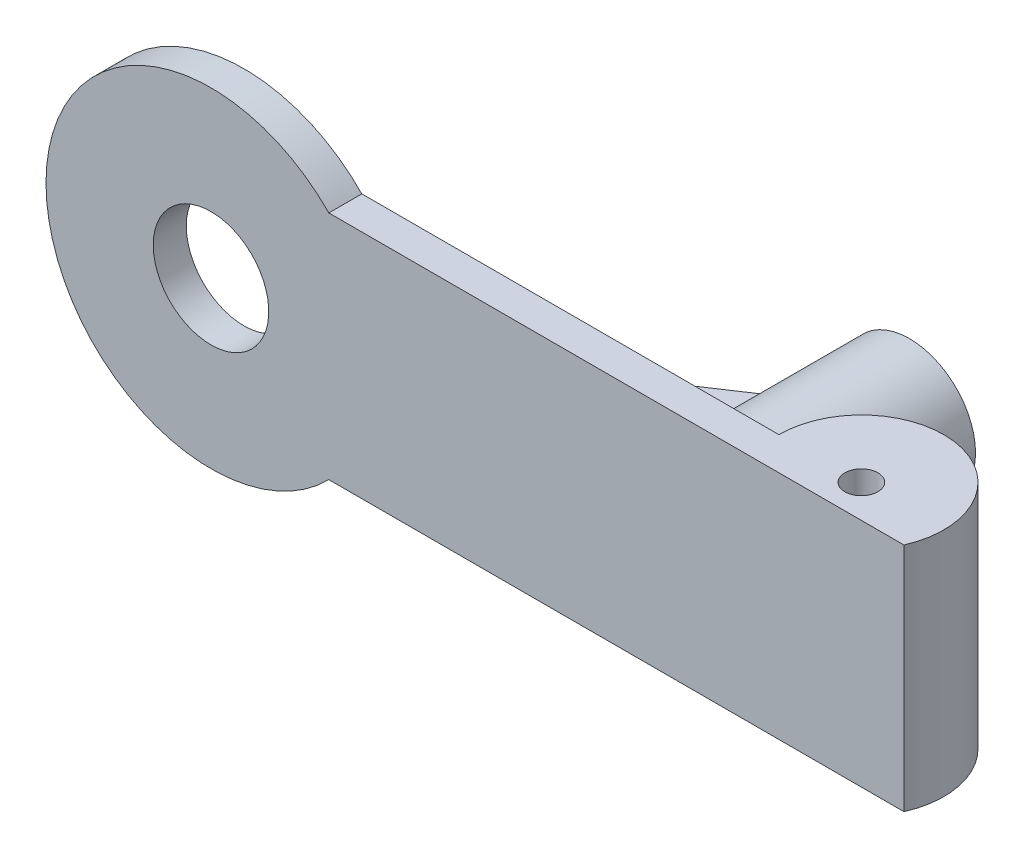
from build123d import *

# Parameters (mm, degrees)
SKETCH1_R           = 5
BOSS_EXTRUDE2_DEPTH = 70
BOSS_EXTRUDE3_DEPTH = 10
SKETCH4_R           = 17.5
CUT_EXTRUDE1_DEPTH  = 10
SKETCH5_R           = 20
SKETCH5_R_2         = 7.5
BOSS_EXTRUDE4_DEPTH = 60
BOSS_EXTRUDE9_DEPTH = 5


with BuildPart() as part:
    # Sketch1 → Boss-Extrude2 (new body)
    with BuildSketch(Plane(origin=(0, 0, 0), x_dir=(1, 0, 0), z_dir=(0, 1, 0))):
        with BuildLine():
            Line((-25, 0), (-187.087121525, 0))
            Line((-187.087121525, 0), (-187.087121525, -10))
            Line((-187.087121525, -10), (22.912878475, -10))
            ThreePointArc((22.912878475, -10), (5.107741092, 24.472657823), (-25, 0))
        make_face()
        Circle(SKETCH1_R, mode=Mode.SUBTRACT)
    extrude(amount=BOSS_EXTRUDE2_DEPTH)

    # Sketch3 → Boss-Extrude3 (add)
    with BuildSketch(Plane(origin=(0, 0, 0), x_dir=(-1, 0, 0), z_dir=(0, 0, -1))):
        with BuildLine():
            ThreePointArc((151.379979383, 70), (137.087121525, 35), (151.379979383, 0))
            Line((151.379979383, 0), (187.087121525, 0))
            Line((187.087121525, 0), (187.087121525, 70))
            Line((187.087121525, 70), (151.379979383, 70))
        make_face()
        with BuildLine():
            Line((187.087121525, 0), (151.379979383, 0))
            ThreePointArc((151.379979383, 0), (205.990069614, -11.289075964), (237.087121525, 35))
            ThreePointArc((237.087121525, 35), (205.990069614, 81.289075964), (151.379979383, 70))
            Line((151.379979383, 70), (187.087121525, 70))
            Line((187.087121525, 70), (187.087121525, 0))
        make_face()
    extrude(amount=-BOSS_EXTRUDE3_DEPTH)

    # Sketch4 → Cut-Extrude1 (cut)
    with BuildSketch(Plane(origin=(0, 0, 0), x_dir=(-1, 0, 0), z_dir=(0, 0, -1))):
        with Locations((187.087121525, 35)):
            Circle(SKETCH4_R)
    extrude(amount=-CUT_EXTRUDE1_DEPTH, mode=Mode.SUBTRACT)

    # Sketch5 → Boss-Extrude4 (add)
    with BuildSketch(Plane(origin=(0, 0, 0), x_dir=(-1, 0, 0), z_dir=(0, 0, -1))):
        with Locations((45.40859007, 35)):
            Circle(SKETCH5_R)
        with Locations((45.40859007, 35)):
            Circle(SKETCH5_R_2, mode=Mode.SUBTRACT)
    extrude(amount=BOSS_EXTRUDE4_DEPTH)


with BuildPart() as body_2:
    # Sketch7 → Boss-Extrude9 (new body, symmetric)
    with BuildSketch(Plane(origin=(0, 35, 0), x_dir=(1, 0, 0), z_dir=(0, 1, 0))):
        Polygon((-65.40859007, 40), (-65.40859007, 0), (-125.40859007, 0), align=None)
    extrude(amount=BOSS_EXTRUDE9_DEPTH, both=True)


solid = Compound([part.part, body_2.part])
